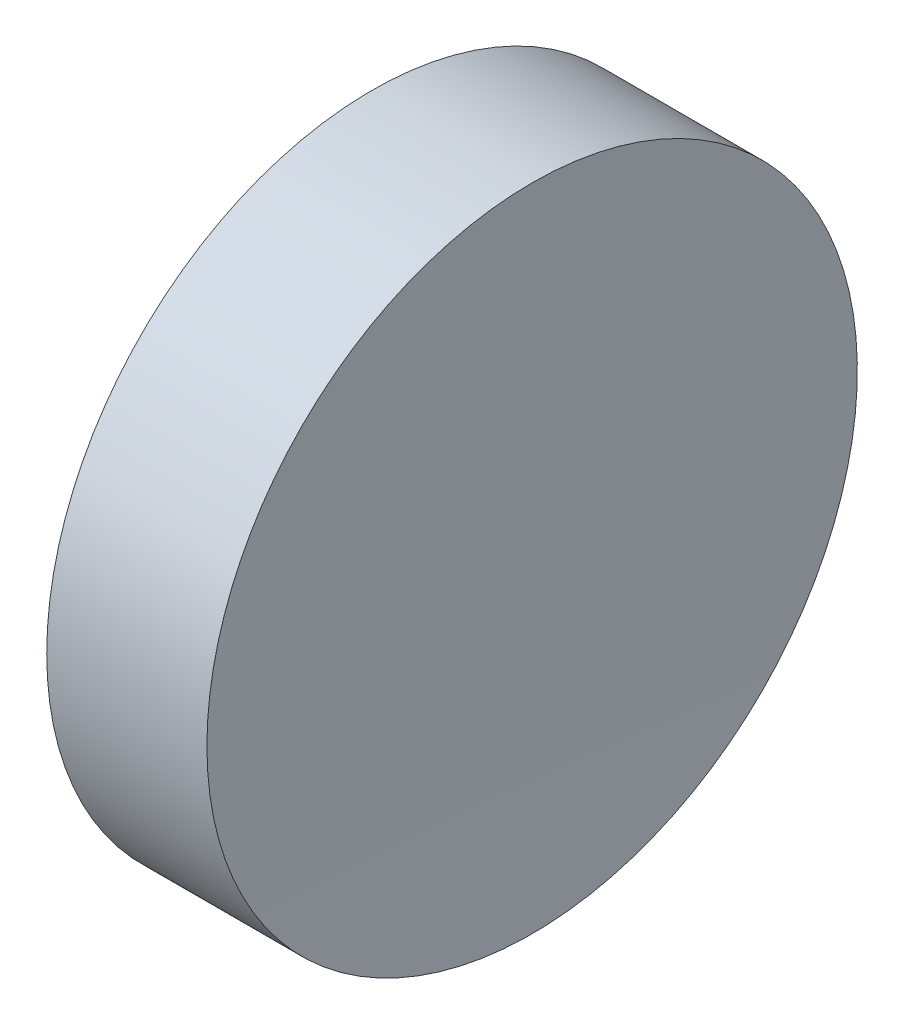
from build123d import *


with BuildPart() as part:
    # 草图1 → 旋转1 (revolve)
    with BuildSketch(Plane.XY):
        with BuildLine():
            Line((115.092655535, 69.378021123), (115.092655535, 81.878021123))
            Line((115.092655535, 81.878021123), (121.248929933, 81.878021123))
            ThreePointArc((121.248929933, 81.878021123), (121.131725644, 75.628509538), (121.092655512, 69.378021123))
            Line((121.092655512, 69.378021123), (115.092655535, 69.378021123))
        make_face()
    revolve(axis=Axis((108.985143002, 69.378021123, 0), (1, 0, 0)))


solid = part.part
